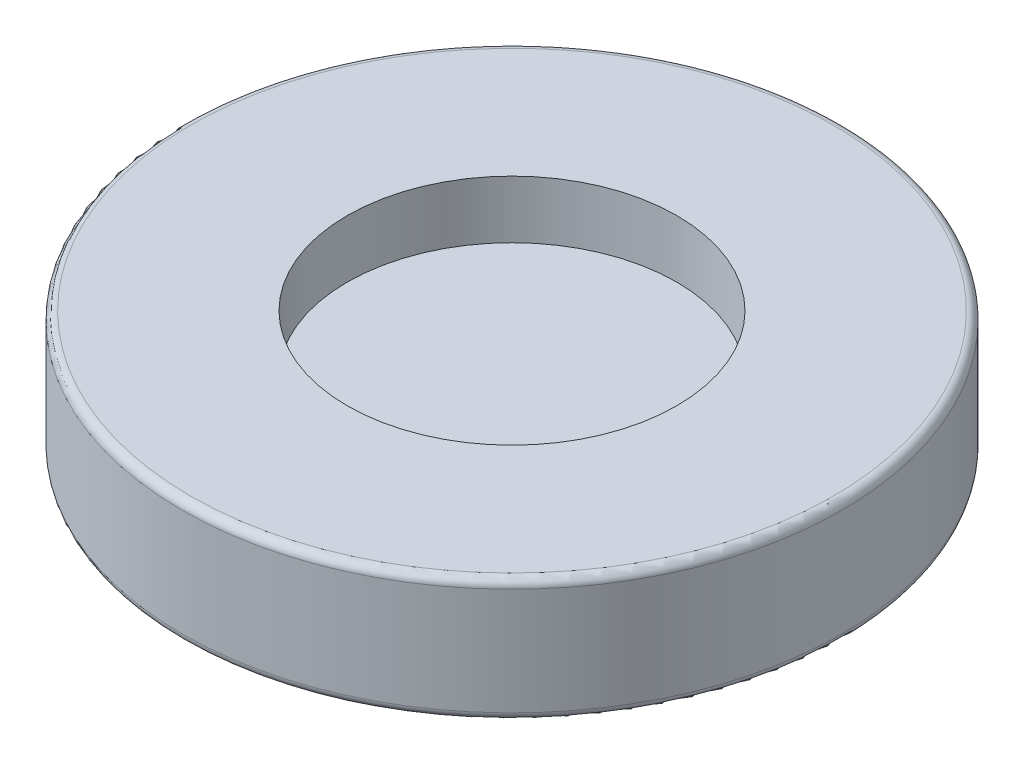
from build123d import *

# Parameters (mm, degrees)
SKETCH1_R           = 4
BOSS_EXTRUDE1_DEPTH = 1.5
SKETCH2_R           = 2
CUT_EXTRUDE1_DEPTH  = 0.7
FILLET2_R           = 0.1
FILLET3_R           = 0.1


with BuildPart() as part:
    # Sketch1 → Boss-Extrude1 (new body)
    with BuildSketch(Plane(origin=(0, 0, 0), x_dir=(1, 0, 0), z_dir=(0, 1, 0))):
        Circle(SKETCH1_R)
    extrude(amount=BOSS_EXTRUDE1_DEPTH)

    # Sketch2 → Cut-Extrude1 (cut)
    with BuildSketch(Plane(origin=(0, 1.5, 0), x_dir=(1, 0, 0), z_dir=(0, 1, 0))):
        Circle(SKETCH2_R)
    extrude(amount=-CUT_EXTRUDE1_DEPTH, mode=Mode.SUBTRACT)

    # Fillet2
    fillet2_edges = [part.edges().sort_by_distance(p)[0] for p in [
        (-4, 0, 0),
    ]]
    fillet(fillet2_edges, radius=FILLET2_R)

    # Fillet3
    fillet3_edges = [part.edges().sort_by_distance(p)[0] for p in [
        (-4, 1.5, 0),
    ]]
    fillet(fillet3_edges, radius=FILLET3_R)


solid = part.part
